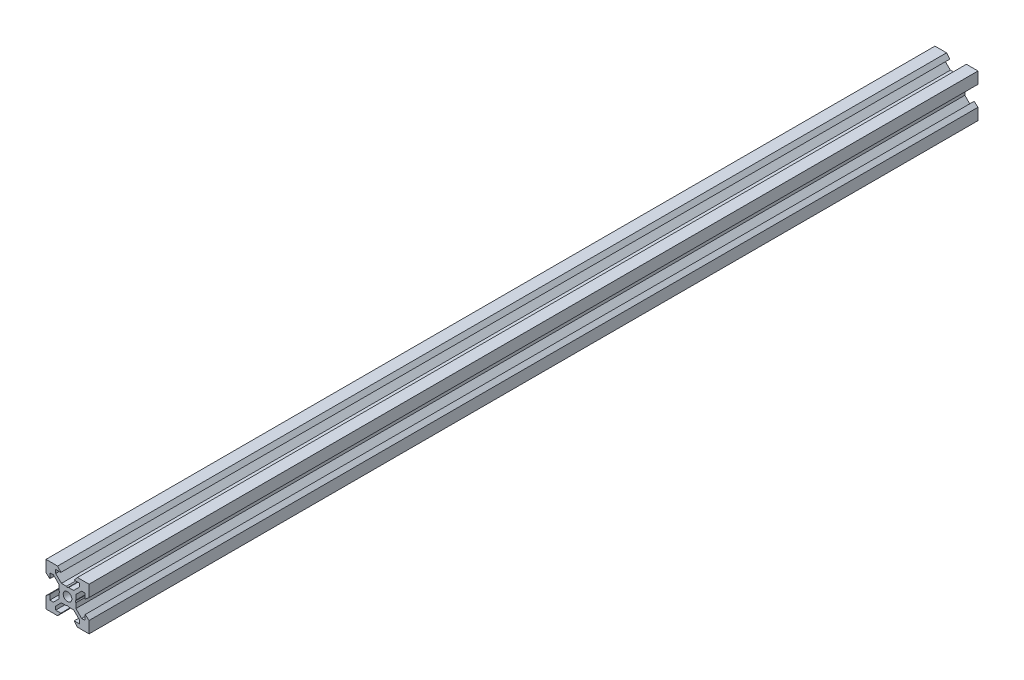
from build123d import *

# Parameters (mm, degrees)
SKETCH1_R           = 2
BOSS_EXTRUDE1_DEPTH = 206.505


with BuildPart() as part:
    # Sketch1 → Boss-Extrude1 (new body, symmetric)
    with BuildSketch(Plane.XY):
        Polygon((10, 10), (10, 4.610379336), (8.2, 3.1), (8.2, 5.5), (6.560660172, 5.5), (3.9, 2.839339828), (3.9, 0.519615242), (3.6, 0), (3.9, -0.519615242), (3.9, -2.839339828), (6.560660172, -5.5), (8.2, -5.5), (8.2, -3.1), (10, -4.610379336), (10, -10), (4.610379336, -10), (3.1, -8.2), (5.5, -8.2), (5.5, -6.560660172), (2.839339828, -3.9), (0.519615242, -3.9), (0, -3.6), (-0.519615242, -3.9), (-2.839339828, -3.9), (-5.5, -6.560660172), (-5.5, -8.2), (-3.1, -8.2), (-4.610379336, -10), (-10, -10), (-10, -4.610379336), (-8.2, -3.1), (-8.2, -5.5), (-6.560660172, -5.5), (-3.9, -2.839339828), (-3.9, -0.519615242), (-3.6, 0), (-3.9, 0.519615242), (-3.9, 2.839339828), (-6.560660172, 5.5), (-8.2, 5.5), (-8.2, 3.1), (-10, 4.610379336), (-10, 10), (-4.610379336, 10), (-3.1, 8.2), (-5.5, 8.2), (-5.5, 6.560660172), (-2.839339828, 3.9), (-0.519615242, 3.9), (0, 3.6), (0.519615242, 3.9), (2.839339828, 3.9), (5.5, 6.560660172), (5.5, 8.2), (3.1, 8.2), (4.610379336, 10), align=None)
        Circle(SKETCH1_R, mode=Mode.SUBTRACT)
    extrude(amount=BOSS_EXTRUDE1_DEPTH, both=True)


solid = part.part
